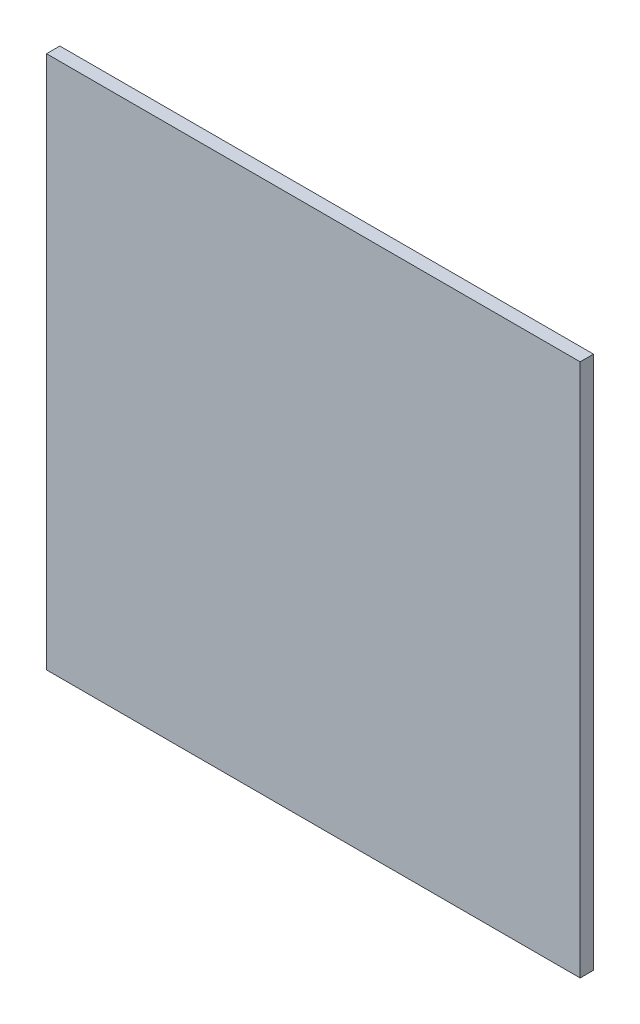
from build123d import *

# Parameters (mm, degrees)
ESBO_O1_W                = 400
ESBO_O1_H                = 400
RESSALTO_EXTRUS_O1_DEPTH = 10


with BuildPart() as part:
    # Esboço1 → Ressalto-extrusão1 (new body)
    with BuildSketch(Plane.XY):
        with Locations((118.691155295, -187.077702703)):
            Rectangle(ESBO_O1_W, ESBO_O1_H)
    extrude(amount=RESSALTO_EXTRUS_O1_DEPTH)


solid = part.part
